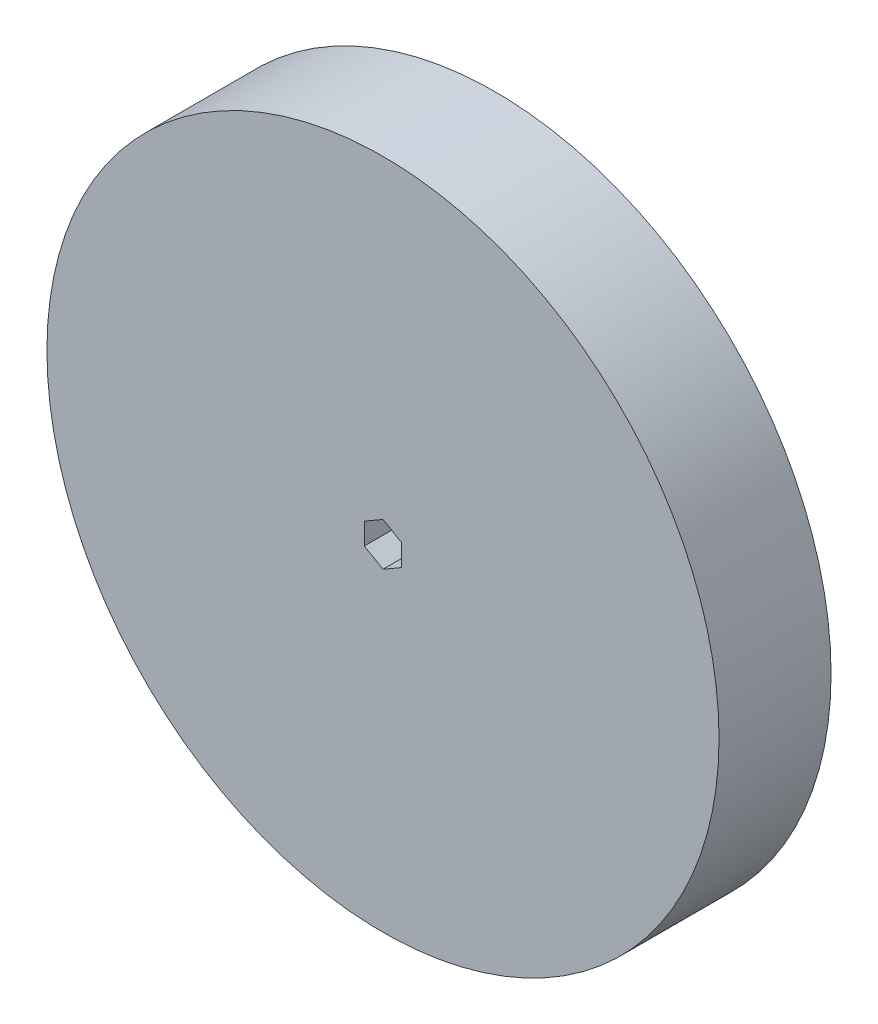
from build123d import *

# Parameters (mm, degrees)
SKETCH2_R           = 57.15
BOSS_EXTRUDE1_DEPTH = 19.05
CUT_EXTRUDE1_DEPTH  = 19.05


with BuildPart() as part:
    # Sketch2 → Boss-Extrude1 (new body)
    with BuildSketch(Plane.XY):
        Circle(SKETCH2_R)
    extrude(amount=BOSS_EXTRUDE1_DEPTH)

    # Sketch4 → Cut-Extrude1 (cut)
    with BuildSketch(Plane(origin=(0, 0, 0), x_dir=(-1, 0, 0), z_dir=(0, 0, -1))):
        Polygon((0, 3.666174209), (-3.175, 1.833087105), (-3.175, -1.833087105), (0, -3.666174209), (3.175, -1.833087105), (3.175, 1.833087105), align=None)
    extrude(amount=-CUT_EXTRUDE1_DEPTH, mode=Mode.SUBTRACT)


solid = part.part
